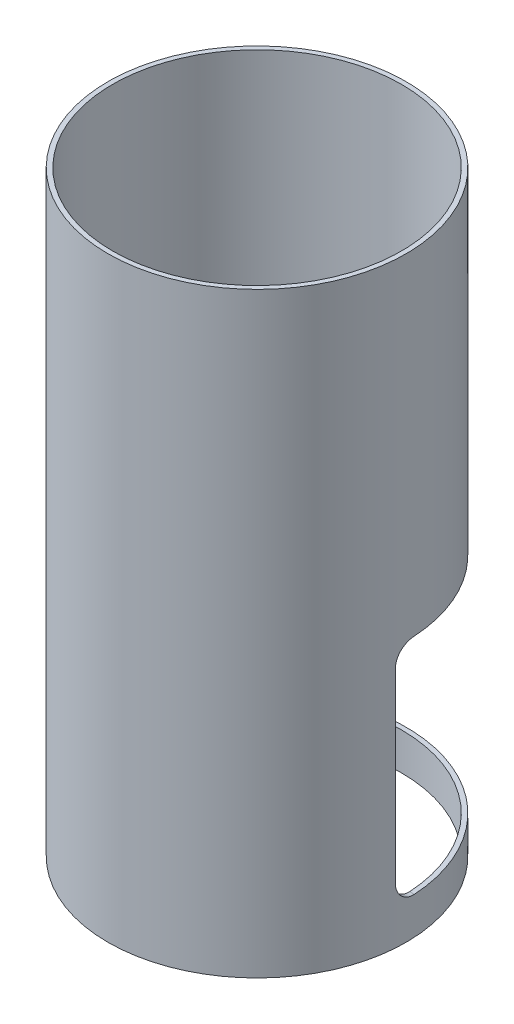
from build123d import *

# Parameters (mm, degrees)
SKETCH1_R           = 101.6
SKETCH1_R_2         = 98.425
BOSS_EXTRUDE1_DEPTH = 406.4
CUT_EXTRUDE2_START  = 25.4
CUT_EXTRUDE2_DEPTH  = 152.4
FILLET1_R           = 12.7


with BuildPart() as part:
    # Sketch1 → Boss-Extrude1 (new body)
    with BuildSketch(Plane(origin=(0, 0, 0), x_dir=(1, 0, 0), z_dir=(0, 1, 0))):
        with Locations(Location((0, 0, 0), (0, 0, 270))):
            Circle(SKETCH1_R)
        with Locations(Location((0, 0, 0), (0, 0, 270))):
            Circle(SKETCH1_R_2, mode=Mode.SUBTRACT)
    extrude(amount=BOSS_EXTRUDE1_DEPTH)

    # Sketch3 → Cut-Extrude2 (cut)
    with BuildSketch(Plane(origin=(0, 0, 0), x_dir=(1, 0, 0), z_dir=(0, 1, 0)).offset(CUT_EXTRUDE2_START)):
        with BuildLine():
            Line((-101.352507506, -7.087257732), (-98.185241647, -6.865780928))
            ThreePointArc((-98.185241647, -6.865780928), (-71.983488082, 67.125688589), (0, 98.425))
            Line((0, 98.425), (0, 101.6))
            ThreePointArc((0, 101.6), (-74.305536085, 69.291033382), (-101.352507506, -7.087257732))
        make_face()
        with BuildLine():
            ThreePointArc((98.425, 0), (98.365042149, -3.434982963), (98.185241647, -6.865780928))
            Line((98.185241647, -6.865780928), (101.352507506, -7.087257732))
            ThreePointArc((101.352507506, -7.087257732), (101.538108025, -3.545788865), (101.6, 0))
            ThreePointArc((101.6, 0), (71.842048969, 71.842048969), (0, 101.6))
            Line((0, 101.6), (0, 98.425))
            ThreePointArc((0, 98.425), (69.596984938, 69.596984938), (98.425, 0))
        make_face()
    extrude(amount=CUT_EXTRUDE2_DEPTH, mode=Mode.SUBTRACT)

    # Fillet1
    fillet1_edges = [part.edges().sort_by_distance(p)[0] for p in [
        (99.768874577, 25.4, 6.97651933),
        (-99.768874577, 177.8, 6.97651933),
        (99.768874577, 177.8, 6.97651933),
        (-99.768874577, 25.4, 6.97651933),
    ]]
    fillet(fillet1_edges, radius=FILLET1_R)


solid = part.part
